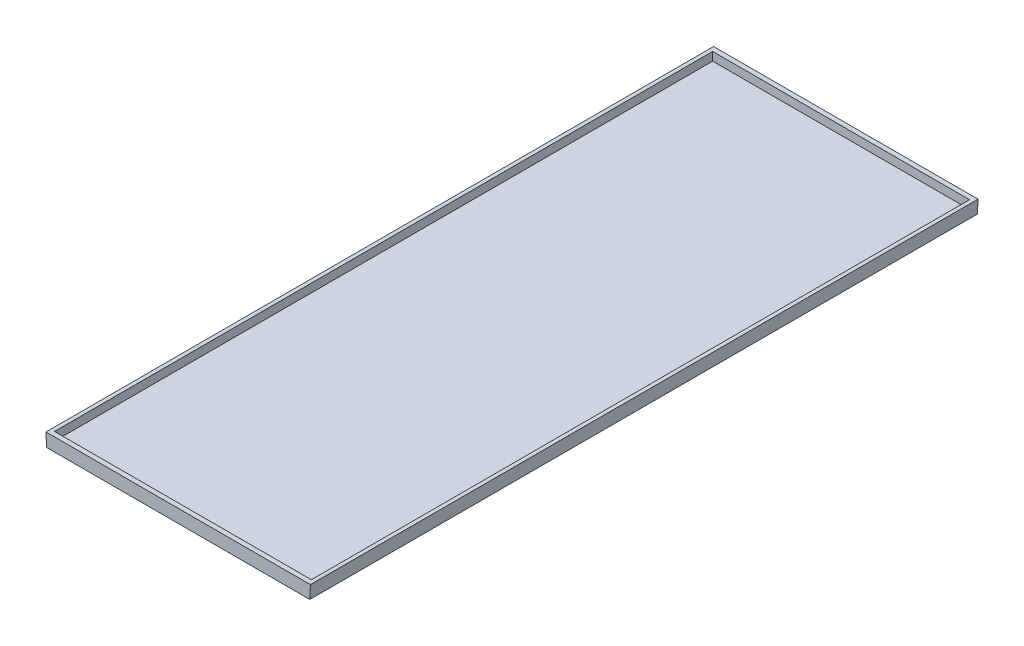
from build123d import *

# Parameters (mm, degrees)
BOSS_EXTRUDE2_DEPTH = 355
SKETCH2_W           = 136.6
SKETCH2_H           = 350
CUT_EXTRUDE1_DEPTH  = 4.5


with BuildPart() as part:
    # Sketch1 → Boss-Extrude2 (new body)
    with BuildSketch(Plane.XY):
        Polygon((-70, -7), (70, -7), (70.3, 0), (-70.3, 0), align=None)
    extrude(amount=BOSS_EXTRUDE2_DEPTH)

    # Sketch2 → Cut-Extrude1 (cut)
    with BuildSketch(Plane(origin=(0, 0, 0), x_dir=(1, 0, 0), z_dir=(0, 1, 0))):
        with Locations((0, -177.5)):
            Rectangle(SKETCH2_W, SKETCH2_H)
    extrude(amount=-CUT_EXTRUDE1_DEPTH, mode=Mode.SUBTRACT)


solid = part.part
